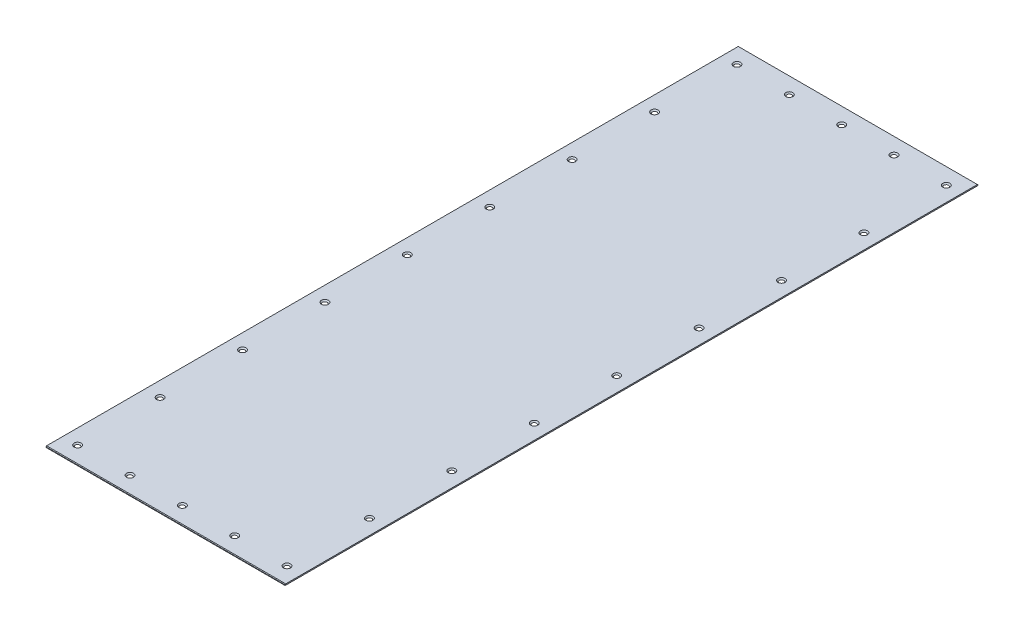
from build123d import *

# Parameters (mm, degrees)
SKETCH1_W                                      = 321
SKETCH1_H                                      = 930
EXTRUDE1_DEPTH                                 = 1.5875
CHAMFER1_SIZE                                  = 0.79375
CSK_FOR_M4_FLAT_HEAD_MACHINE_SCREW1_AT_2_COUNT = 2
CSK_FOR_M4_FLAT_HEAD_MACHINE_SCREW1_AT_2_PITCH = 70.25
CSK_FOR_M4_FLAT_HEAD_MACHINE_SCREW1_AT_3_COUNT = 2
CSK_FOR_M4_FLAT_HEAD_MACHINE_SCREW1_AT_3_PITCH = 140.5
CSK_FOR_M4_FLAT_HEAD_MACHINE_SCREW1_AT_4_COUNT = 2
CSK_FOR_M4_FLAT_HEAD_MACHINE_SCREW1_AT_4_PITCH = 210.75
CSK_FOR_M4_FLAT_HEAD_MACHINE_SCREW1_AT_5_COUNT = 2
CSK_FOR_M4_FLAT_HEAD_MACHINE_SCREW1_AT_5_PITCH = 281
CSK_FOR_M4_FLAT_HEAD_MACHINE_SCREW1_AT_6_COUNT = 2
CSK_FOR_M4_FLAT_HEAD_MACHINE_SCREW1_AT_6_PITCH = 110.625
CSK_FOR_M4_FLAT_HEAD_MACHINE_SCREW1_AT_7_COUNT = 2
CSK_FOR_M4_FLAT_HEAD_MACHINE_SCREW1_AT_7_PITCH = 301.991540651
CSK_FOR_M4_FLAT_HEAD_MACHINE_SCREW1_AT_8_COUNT = 2
CSK_FOR_M4_FLAT_HEAD_MACHINE_SCREW1_AT_8_PITCH = 221.25
CSK_FOR_M4_FLAT_HEAD_MACHINE_SCREW1_AT_9_COUNT = 2
CSK_FOR_M4_FLAT_HEAD_MACHINE_SCREW1_AT_9_PITCH = 357.648657903
CSK_FOR_M4_FLAT_HEAD_MACHINE_SCREW1_AT_1_COUNT = 2
CSK_FOR_M4_FLAT_HEAD_MACHINE_SCREW1_AT_1_PITCH = 331.875
CSK_FOR_M4_FLAT_HEAD_MACHINE_SCREW1_2_COUNT    = 2
CSK_FOR_M4_FLAT_HEAD_MACHINE_SCREW1_2_PITCH    = 434.858615673
CSK_FOR_M4_FLAT_HEAD_MACHINE_SCREW1_3_COUNT    = 2
CSK_FOR_M4_FLAT_HEAD_MACHINE_SCREW1_3_PITCH    = 442.5
CSK_FOR_M4_FLAT_HEAD_MACHINE_SCREW1_4_COUNT    = 2
CSK_FOR_M4_FLAT_HEAD_MACHINE_SCREW1_4_PITCH    = 524.182458692
CSK_FOR_M4_FLAT_HEAD_MACHINE_SCREW1_5_COUNT    = 2
CSK_FOR_M4_FLAT_HEAD_MACHINE_SCREW1_5_PITCH    = 553.125
CSK_FOR_M4_FLAT_HEAD_MACHINE_SCREW1_6_COUNT    = 2
CSK_FOR_M4_FLAT_HEAD_MACHINE_SCREW1_6_PITCH    = 663.75
CSK_FOR_M4_FLAT_HEAD_MACHINE_SCREW1_7_COUNT    = 2
CSK_FOR_M4_FLAT_HEAD_MACHINE_SCREW1_7_PITCH    = 774.375
CSK_FOR_M4_FLAT_HEAD_MACHINE_SCREW1_8_COUNT    = 2
CSK_FOR_M4_FLAT_HEAD_MACHINE_SCREW1_8_PITCH    = 620.40975623
CSK_FOR_M4_FLAT_HEAD_MACHINE_SCREW1_9_COUNT    = 2
CSK_FOR_M4_FLAT_HEAD_MACHINE_SCREW1_9_PITCH    = 720.78086996
CSK_FOR_M4_FLAT_HEAD_MACHINE_SCREW1_10_COUNT   = 2
CSK_FOR_M4_FLAT_HEAD_MACHINE_SCREW1_10_PITCH   = 823.782520223
CSK_FOR_M4_FLAT_HEAD_MACHINE_SCREW1_11_COUNT   = 2
CSK_FOR_M4_FLAT_HEAD_MACHINE_SCREW1_11_PITCH   = 885
CSK_FOR_M4_FLAT_HEAD_MACHINE_SCREW1_12_COUNT   = 2
CSK_FOR_M4_FLAT_HEAD_MACHINE_SCREW1_12_PITCH   = 887.783792654
CSK_FOR_M4_FLAT_HEAD_MACHINE_SCREW1_13_COUNT   = 2
CSK_FOR_M4_FLAT_HEAD_MACHINE_SCREW1_13_PITCH   = 896.08328296
CSK_FOR_M4_FLAT_HEAD_MACHINE_SCREW1_14_COUNT   = 2
CSK_FOR_M4_FLAT_HEAD_MACHINE_SCREW1_14_PITCH   = 909.74752679
CSK_FOR_M4_FLAT_HEAD_MACHINE_SCREW1_15_COUNT   = 2
CSK_FOR_M4_FLAT_HEAD_MACHINE_SCREW1_15_PITCH   = 928.539713744


with BuildPart() as part:
    # Sketch1 → Extrude1 (new body)
    with BuildSketch(Plane(origin=(0, 0, 0), x_dir=(1, 0, 0), z_dir=(0, 1, 0))):
        Rectangle(SKETCH1_W, SKETCH1_H)
    extrude(amount=EXTRUDE1_DEPTH)

    # Chamfer1
    chamfer1_edges = [part.edges().sort_by_distance(p)[0] for p in [
        (0, 1.5875, 465),
        (0, 1.5875, -465),
    ]]
    chamfer(chamfer1_edges, length=CHAMFER1_SIZE)

    # Sketch3 → CSK for M4 Flat Head Machine Screw1 (revolve, cut)
    with BuildSketch(Plane(origin=(-140.5, 1.5875, -442.5), x_dir=(0, 0, 1), z_dir=(1, 0, 0))):
        Polygon((0, 0), (0, 1.5875), (2.25, 1.5875), (2.25, 2.45), (4.7, 0), align=None)
    csk_for_m4_flat_head_machine_screw1 = revolve(axis=Axis((-140.5, 7.9375, -442.5), (0, -1, 0)), mode=Mode.SUBTRACT)

    # CSK for M4 Flat Head Machine Screw1 at 2: CSK for M4 Flat Head Machine Screw1 ×2
    with Locations(*[(i * CSK_FOR_M4_FLAT_HEAD_MACHINE_SCREW1_AT_2_PITCH, 0, 0) for i in range(1, CSK_FOR_M4_FLAT_HEAD_MACHINE_SCREW1_AT_2_COUNT)]):
        add(csk_for_m4_flat_head_machine_screw1, mode=Mode.SUBTRACT)

    # CSK for M4 Flat Head Machine Screw1 at 3: CSK for M4 Flat Head Machine Screw1 ×2
    with Locations(*[(i * CSK_FOR_M4_FLAT_HEAD_MACHINE_SCREW1_AT_3_PITCH, 0, 0) for i in range(1, CSK_FOR_M4_FLAT_HEAD_MACHINE_SCREW1_AT_3_COUNT)]):
        add(csk_for_m4_flat_head_machine_screw1, mode=Mode.SUBTRACT)

    # CSK for M4 Flat Head Machine Screw1 at 4: CSK for M4 Flat Head Machine Screw1 ×2
    with Locations(*[(i * CSK_FOR_M4_FLAT_HEAD_MACHINE_SCREW1_AT_4_PITCH, 0, 0) for i in range(1, CSK_FOR_M4_FLAT_HEAD_MACHINE_SCREW1_AT_4_COUNT)]):
        add(csk_for_m4_flat_head_machine_screw1, mode=Mode.SUBTRACT)

    # CSK for M4 Flat Head Machine Screw1 at 5: CSK for M4 Flat Head Machine Screw1 ×2
    with Locations(*[(i * CSK_FOR_M4_FLAT_HEAD_MACHINE_SCREW1_AT_5_PITCH, 0, 0) for i in range(1, CSK_FOR_M4_FLAT_HEAD_MACHINE_SCREW1_AT_5_COUNT)]):
        add(csk_for_m4_flat_head_machine_screw1, mode=Mode.SUBTRACT)

    # CSK for M4 Flat Head Machine Screw1 at 6: CSK for M4 Flat Head Machine Screw1 ×2
    with Locations(*[(0, 0, i * CSK_FOR_M4_FLAT_HEAD_MACHINE_SCREW1_AT_6_PITCH) for i in range(1, CSK_FOR_M4_FLAT_HEAD_MACHINE_SCREW1_AT_6_COUNT)]):
        add(csk_for_m4_flat_head_machine_screw1, mode=Mode.SUBTRACT)

    # CSK for M4 Flat Head Machine Screw1 at 7: CSK for M4 Flat Head Machine Screw1 ×2
    with Locations(*[Vector(0.93048964, 0, 0.366318208) * (i * CSK_FOR_M4_FLAT_HEAD_MACHINE_SCREW1_AT_7_PITCH) for i in range(1, CSK_FOR_M4_FLAT_HEAD_MACHINE_SCREW1_AT_7_COUNT)]):
        add(csk_for_m4_flat_head_machine_screw1, mode=Mode.SUBTRACT)

    # CSK for M4 Flat Head Machine Screw1 at 8: CSK for M4 Flat Head Machine Screw1 ×2
    with Locations(*[(0, 0, i * CSK_FOR_M4_FLAT_HEAD_MACHINE_SCREW1_AT_8_PITCH) for i in range(1, CSK_FOR_M4_FLAT_HEAD_MACHINE_SCREW1_AT_8_COUNT)]):
        add(csk_for_m4_flat_head_machine_screw1, mode=Mode.SUBTRACT)

    # CSK for M4 Flat Head Machine Screw1 at 9: CSK for M4 Flat Head Machine Screw1 ×2
    with Locations(*[Vector(0.785687277, 0, 0.618623879) * (i * CSK_FOR_M4_FLAT_HEAD_MACHINE_SCREW1_AT_9_PITCH) for i in range(1, CSK_FOR_M4_FLAT_HEAD_MACHINE_SCREW1_AT_9_COUNT)]):
        add(csk_for_m4_flat_head_machine_screw1, mode=Mode.SUBTRACT)

    # CSK for M4 Flat Head Machine Screw1 at 1: CSK for M4 Flat Head Machine Screw1 ×2
    with Locations(*[(0, 0, i * CSK_FOR_M4_FLAT_HEAD_MACHINE_SCREW1_AT_1_PITCH) for i in range(1, CSK_FOR_M4_FLAT_HEAD_MACHINE_SCREW1_AT_1_COUNT)]):
        add(csk_for_m4_flat_head_machine_screw1, mode=Mode.SUBTRACT)

    # CSK for M4 Flat Head Machine Screw1  2: CSK for M4 Flat Head Machine Screw1 ×2
    with Locations(*[Vector(0.646187036, 0, 0.763179084) * (i * CSK_FOR_M4_FLAT_HEAD_MACHINE_SCREW1_2_PITCH) for i in range(1, CSK_FOR_M4_FLAT_HEAD_MACHINE_SCREW1_2_COUNT)]):
        add(csk_for_m4_flat_head_machine_screw1, mode=Mode.SUBTRACT)

    # CSK for M4 Flat Head Machine Screw1  3: CSK for M4 Flat Head Machine Screw1 ×2
    with Locations(*[(0, 0, i * CSK_FOR_M4_FLAT_HEAD_MACHINE_SCREW1_3_PITCH) for i in range(1, CSK_FOR_M4_FLAT_HEAD_MACHINE_SCREW1_3_COUNT)]):
        add(csk_for_m4_flat_head_machine_screw1, mode=Mode.SUBTRACT)

    # CSK for M4 Flat Head Machine Screw1  4: CSK for M4 Flat Head Machine Screw1 ×2
    with Locations(*[Vector(0.536072879, 0, 0.844171705) * (i * CSK_FOR_M4_FLAT_HEAD_MACHINE_SCREW1_4_PITCH) for i in range(1, CSK_FOR_M4_FLAT_HEAD_MACHINE_SCREW1_4_COUNT)]):
        add(csk_for_m4_flat_head_machine_screw1, mode=Mode.SUBTRACT)

    # CSK for M4 Flat Head Machine Screw1  5: CSK for M4 Flat Head Machine Screw1 ×2
    with Locations(*[(0, 0, i * CSK_FOR_M4_FLAT_HEAD_MACHINE_SCREW1_5_PITCH) for i in range(1, CSK_FOR_M4_FLAT_HEAD_MACHINE_SCREW1_5_COUNT)]):
        add(csk_for_m4_flat_head_machine_screw1, mode=Mode.SUBTRACT)

    # CSK for M4 Flat Head Machine Screw1  6: CSK for M4 Flat Head Machine Screw1 ×2
    with Locations(*[(0, 0, i * CSK_FOR_M4_FLAT_HEAD_MACHINE_SCREW1_6_PITCH) for i in range(1, CSK_FOR_M4_FLAT_HEAD_MACHINE_SCREW1_6_COUNT)]):
        add(csk_for_m4_flat_head_machine_screw1, mode=Mode.SUBTRACT)

    # CSK for M4 Flat Head Machine Screw1  7: CSK for M4 Flat Head Machine Screw1 ×2
    with Locations(*[(0, 0, i * CSK_FOR_M4_FLAT_HEAD_MACHINE_SCREW1_7_PITCH) for i in range(1, CSK_FOR_M4_FLAT_HEAD_MACHINE_SCREW1_7_COUNT)]):
        add(csk_for_m4_flat_head_machine_screw1, mode=Mode.SUBTRACT)

    # CSK for M4 Flat Head Machine Screw1  8: CSK for M4 Flat Head Machine Screw1 ×2
    with Locations(*[Vector(0.452926469, 0, 0.891547875) * (i * CSK_FOR_M4_FLAT_HEAD_MACHINE_SCREW1_8_PITCH) for i in range(1, CSK_FOR_M4_FLAT_HEAD_MACHINE_SCREW1_8_COUNT)]):
        add(csk_for_m4_flat_head_machine_screw1, mode=Mode.SUBTRACT)

    # CSK for M4 Flat Head Machine Screw1  9: CSK for M4 Flat Head Machine Screw1 ×2
    with Locations(*[Vector(0.389854964, 0, 0.920876271) * (i * CSK_FOR_M4_FLAT_HEAD_MACHINE_SCREW1_9_PITCH) for i in range(1, CSK_FOR_M4_FLAT_HEAD_MACHINE_SCREW1_9_COUNT)]):
        add(csk_for_m4_flat_head_machine_screw1, mode=Mode.SUBTRACT)

    # CSK for M4 Flat Head Machine Screw1  10: CSK for M4 Flat Head Machine Screw1 ×2
    with Locations(*[Vector(0.341109447, 0, 0.940023588) * (i * CSK_FOR_M4_FLAT_HEAD_MACHINE_SCREW1_10_PITCH) for i in range(1, CSK_FOR_M4_FLAT_HEAD_MACHINE_SCREW1_10_COUNT)]):
        add(csk_for_m4_flat_head_machine_screw1, mode=Mode.SUBTRACT)

    # CSK for M4 Flat Head Machine Screw1  11: CSK for M4 Flat Head Machine Screw1 ×2
    with Locations(*[(0, 0, i * CSK_FOR_M4_FLAT_HEAD_MACHINE_SCREW1_11_PITCH) for i in range(1, CSK_FOR_M4_FLAT_HEAD_MACHINE_SCREW1_11_COUNT)]):
        add(csk_for_m4_flat_head_machine_screw1, mode=Mode.SUBTRACT)

    # CSK for M4 Flat Head Machine Screw1  12: CSK for M4 Flat Head Machine Screw1 ×2
    with Locations(*[Vector(0.079129627, 0, 0.996864335) * (i * CSK_FOR_M4_FLAT_HEAD_MACHINE_SCREW1_12_PITCH) for i in range(1, CSK_FOR_M4_FLAT_HEAD_MACHINE_SCREW1_12_COUNT)]):
        add(csk_for_m4_flat_head_machine_screw1, mode=Mode.SUBTRACT)

    # CSK for M4 Flat Head Machine Screw1  13: CSK for M4 Flat Head Machine Screw1 ×2
    with Locations(*[Vector(0.156793462, 0, 0.987631414) * (i * CSK_FOR_M4_FLAT_HEAD_MACHINE_SCREW1_13_PITCH) for i in range(1, CSK_FOR_M4_FLAT_HEAD_MACHINE_SCREW1_13_COUNT)]):
        add(csk_for_m4_flat_head_machine_screw1, mode=Mode.SUBTRACT)

    # CSK for M4 Flat Head Machine Screw1  14: CSK for M4 Flat Head Machine Screw1 ×2
    with Locations(*[Vector(0.231657678, 0, 0.972797368) * (i * CSK_FOR_M4_FLAT_HEAD_MACHINE_SCREW1_14_PITCH) for i in range(1, CSK_FOR_M4_FLAT_HEAD_MACHINE_SCREW1_14_COUNT)]):
        add(csk_for_m4_flat_head_machine_screw1, mode=Mode.SUBTRACT)

    # CSK for M4 Flat Head Machine Screw1  15: CSK for M4 Flat Head Machine Screw1 ×2
    with Locations(*[Vector(0.302625721, 0, 0.953109476) * (i * CSK_FOR_M4_FLAT_HEAD_MACHINE_SCREW1_15_PITCH) for i in range(1, CSK_FOR_M4_FLAT_HEAD_MACHINE_SCREW1_15_COUNT)]):
        add(csk_for_m4_flat_head_machine_screw1, mode=Mode.SUBTRACT)


solid = part.part
